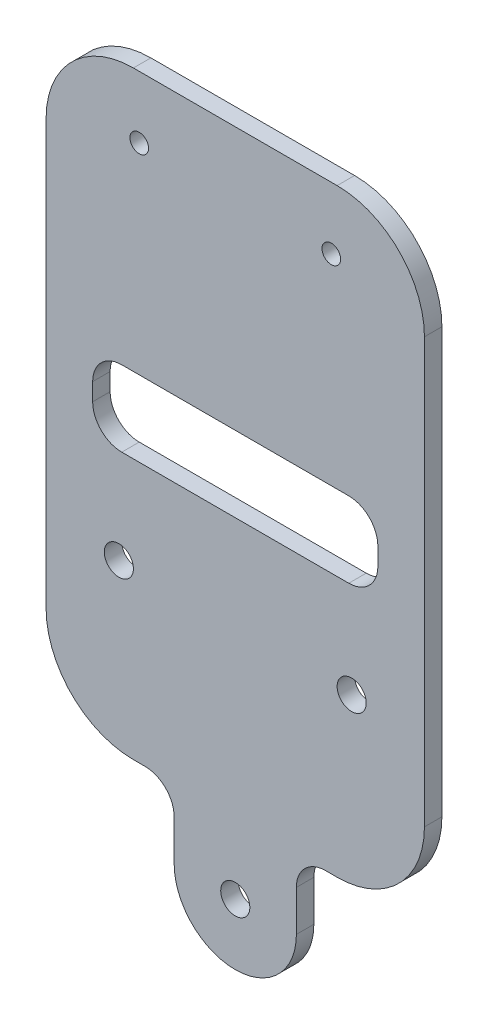
from build123d import *

# Parameters (mm, degrees)
SKETCH2_W           = 200
SKETCH2_H           = 200
BOSS_EXTRUDE1_DEPTH = 3
SKETCH3_R           = 2.5
CUT_EXTRUDE1_DEPTH  = 10
CUT_EXTRUDE2_REACH  = 143.453
SKETCH4_W           = 200
SKETCH4_H           = 200
SKETCH4_W_2         = 49
SKETCH4_H_2         = 13
FILLET1_R           = 15
FILLET2_R           = 5
CUT_EXTRUDE4_REACH  = 99.207
SKETCH6_R           = 1.6


with BuildPart() as part:
    # Sketch2 → Boss-Extrude1 (new body)
    with BuildSketch(Plane.XY):
        Rectangle(SKETCH2_W, SKETCH2_H)
    extrude(amount=BOSS_EXTRUDE1_DEPTH)

    # Sketch3 → Cut-Extrude1 (cut)
    with BuildSketch(Plane(origin=(0, 0, 0), x_dir=(-1, 0, 0), z_dir=(0, 0, -1))):
        with Locations((-32.4, 11.65)):
            Circle(SKETCH3_R)
        with Locations((7.6, 11.65)):
            Circle(SKETCH3_R)
        with Locations((-12.4, -28.75)):
            Circle(SKETCH3_R)
    extrude(amount=-CUT_EXTRUDE1_DEPTH, mode=Mode.SUBTRACT)

    # Sketch4 → Cut-Extrude2 (cut, up to next)
    with BuildSketch(Plane.XY.offset(3), mode=Mode.PRIVATE) as cut_extrude2_sk1:
        Rectangle(SKETCH4_W, SKETCH4_H)
        with BuildLine():
            Line((-20.1, -16.75), (-20.1, 86.163533864))
            Line((-20.1, 86.163533864), (44.9, 86.163533864))
            Line((44.9, 86.163533864), (44.9, -16.75))
            Line((44.9, -16.75), (22.9, -16.75))
            Line((22.9, -16.75), (22.9, -28.75))
            ThreePointArc((22.9, -28.75), (12.4, -39.25), (1.9, -28.75))
            Line((1.9, -28.75), (1.9, -16.75))
            Line((1.9, -16.75), (-20.1, -16.75))
        make_face(mode=Mode.SUBTRACT)
    cut_extrude2_tool1 = extrude(cut_extrude2_sk1.sketch, amount=-CUT_EXTRUDE2_REACH, mode=Mode.PRIVATE) & part.part
    # Sketch4 → Cut-Extrude2 (cut, up to next)
    with BuildSketch(Plane.XY.offset(3), mode=Mode.PRIVATE) as cut_extrude2_sk2:
        with Locations((12.4, 34.5)):
            Rectangle(SKETCH4_W_2, SKETCH4_H_2)
    cut_extrude2_tool2 = extrude(cut_extrude2_sk2.sketch, amount=-CUT_EXTRUDE2_REACH, mode=Mode.PRIVATE) & part.part
    add(cut_extrude2_tool1.solids().sort_by_distance((-97.171573, 0, 3))[0], mode=Mode.SUBTRACT)
    add(cut_extrude2_tool2.solids().sort_by_distance((12.4, 34.5, 3))[0], mode=Mode.SUBTRACT)

    # Fillet1
    fillet1_edges = [part.edges().sort_by_distance(p)[0] for p in [
        (-20.1, -16.75, 1.5),
        (44.9, -16.75, 1.5),
        (-20.1, 86.163533864, 1.5),
        (44.9, 86.163533864, 1.5),
    ]]
    fillet(fillet1_edges, radius=FILLET1_R)

    # Fillet2
    fillet2_edges = [part.edges().sort_by_distance(p)[0] for p in [
        (-12.1, 41, 1.5),
        (-12.1, 28, 1.5),
        (36.9, 41, 1.5),
        (36.9, 28, 1.5),
        (1.9, -16.75, 1.5),
        (22.9, -16.75, 1.5),
    ]]
    fillet(fillet2_edges, radius=FILLET2_R)

    # Sketch6 → Cut-Extrude4 (cut, up to next)
    with BuildSketch(Plane.XY.offset(3), mode=Mode.PRIVATE) as cut_extrude4_sk1:
        with Locations((-4.1, 75.5)):
            Circle(SKETCH6_R)
    cut_extrude4_tool1 = extrude(cut_extrude4_sk1.sketch, amount=-CUT_EXTRUDE4_REACH, mode=Mode.PRIVATE) & part.part
    # Sketch6 → Cut-Extrude4 (cut, up to next)
    with BuildSketch(Plane.XY.offset(3), mode=Mode.PRIVATE) as cut_extrude4_sk2:
        with Locations((28.9, 75.5)):
            Circle(SKETCH6_R)
    cut_extrude4_tool2 = extrude(cut_extrude4_sk2.sketch, amount=-CUT_EXTRUDE4_REACH, mode=Mode.PRIVATE) & part.part
    add(cut_extrude4_tool1.solids().sort_by_distance((-4.1, 75.5, 3))[0], mode=Mode.SUBTRACT)
    add(cut_extrude4_tool2.solids().sort_by_distance((28.9, 75.5, 3))[0], mode=Mode.SUBTRACT)


solid = part.part
